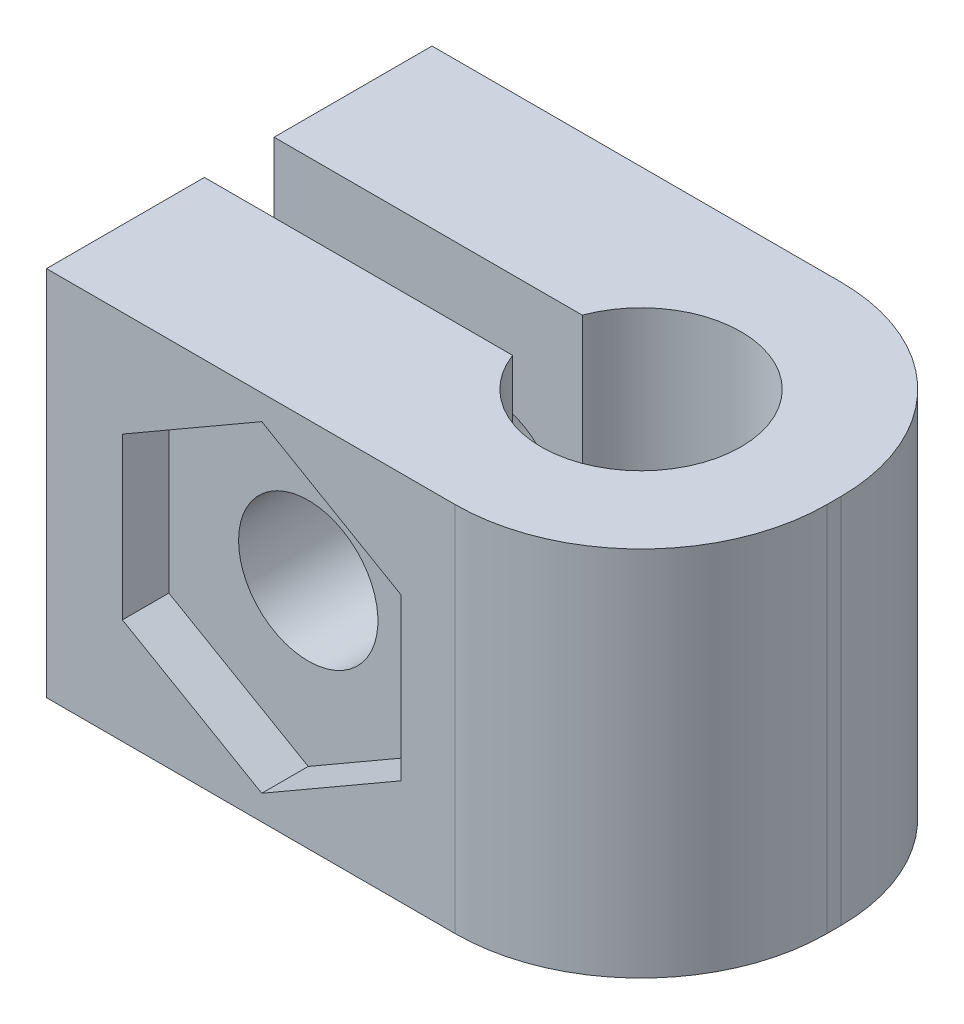
from build123d import *

# Parameters (mm, degrees)
BOSS_EXTRUDE1_DEPTH     = 8
SKETCH2_R               = 1.5
CUT_EXTRUDE1_DEPTH      = 5.9
CUT_EXTRUDE1_DEPTH_BACK = 4.4
CUT_EXTRUDE2_START      = 4.9
SKETCH2_3_R             = 1.5
CUT_EXTRUDE2_DEPTH      = 1
SKETCH3_R               = 3
CUT_EXTRUDE3_DEPTH      = 1
FILLET1_R               = 4


with BuildPart() as part:
    # Sketch1 → Boss-Extrude1 (new body)
    with BuildSketch(Plane(origin=(0, 0, 0), x_dir=(1, 0, 0), z_dir=(0, 1, 0))):
        with BuildLine():
            Line((-8.65, -0.75), (-8.65, -4.15))
            Line((-8.65, -4.15), (4.15, -4.15))
            Line((4.15, -4.15), (4.15, 4.15))
            Line((4.15, 4.15), (-8.65, 4.15))
            Line((-8.65, 4.15), (-8.65, 0.75))
            Line((-8.65, 0.75), (-2.014944168, 0.75))
            ThreePointArc((-2.014944168, 0.75), (0.38103152, 2.115966678), (2.15, 0))
            ThreePointArc((2.15, 0), (0.38103152, -2.115966678), (-2.014944168, -0.75))
            Line((-2.014944168, -0.75), (-8.65, -0.75))
        make_face()
    extrude(amount=BOSS_EXTRUDE1_DEPTH)

    # Sketch2 → Cut-Extrude1 (cut, two sides)
    with BuildSketch(Plane.XY.offset(-0.75)) as cut_extrude1_sk:
        with Locations((-4.014944168, 4)):
            Circle(SKETCH2_R)
    extrude(amount=CUT_EXTRUDE1_DEPTH, mode=Mode.SUBTRACT)
    extrude(cut_extrude1_sk.sketch, amount=-CUT_EXTRUDE1_DEPTH_BACK, mode=Mode.SUBTRACT)

    # Sketch2_3 → Cut-Extrude2 (cut)
    with BuildSketch(Plane.XY.offset(-0.75).offset(CUT_EXTRUDE2_START)):
        Polygon((-2.014944168, 6.309401077), (-4.014944168, 7.464101615), (-7.014944168, 5.732050808), (-7.014944168, 2.267949192), (-4.014944168, 0.535898385), (-2.014944168, 1.690598923), align=None)
        with Locations((-4.014944168, 4)):
            Circle(SKETCH2_3_R, mode=Mode.SUBTRACT)
        Polygon((-1.014944168, 5.732050808), (-2.014944168, 6.309401077), (-2.014944168, 1.690598923), (-1.014944168, 2.267949192), align=None)
    extrude(amount=-CUT_EXTRUDE2_DEPTH, mode=Mode.SUBTRACT)

    # Sketch3 → Cut-Extrude3 (cut)
    with BuildSketch(Plane(origin=(0, 0, -4.15), x_dir=(-1, 0, 0), z_dir=(0, 0, -1))):
        with Locations((4.014944168, 4)):
            Circle(SKETCH3_R)
    extrude(amount=-CUT_EXTRUDE3_DEPTH, mode=Mode.SUBTRACT)

    # Fillet1
    fillet1_edges = [part.edges().sort_by_distance(p)[0] for p in [
        (4.15, 4, -4.15),
        (4.15, 4, 4.15),
    ]]
    fillet(fillet1_edges, radius=FILLET1_R)


solid = part.part
